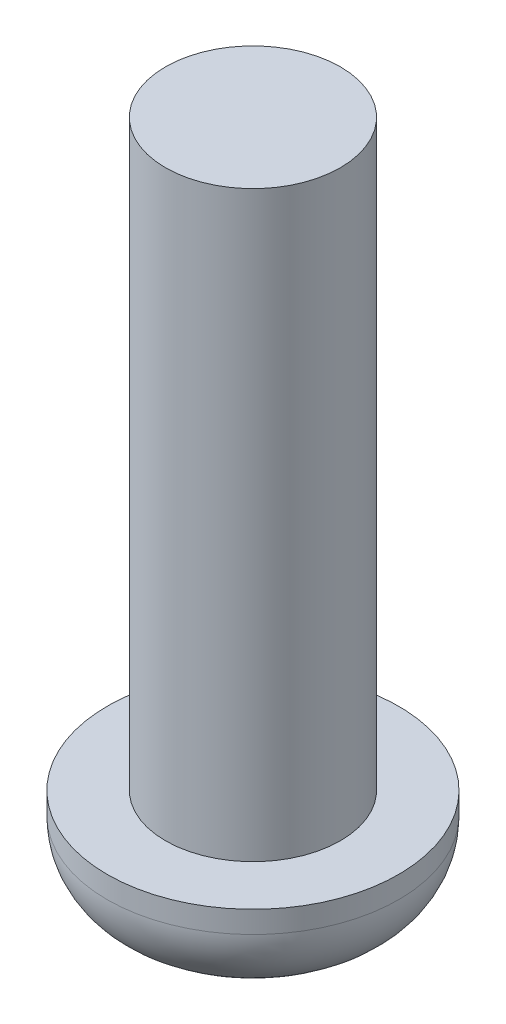
from build123d import *

# Parameters (mm, degrees)
SKETCH1_R           = 4
BOSS_EXTRUDE1_DEPTH = 2.6
SKETCH2_R           = 2.4
BOSS_EXTRUDE2_DEPTH = 16
FILLET1_R           = 2


with BuildPart() as part:
    # Sketch1 → Boss-Extrude1 (new body)
    with BuildSketch(Plane(origin=(0, 0, 0), x_dir=(1, 0, 0), z_dir=(0, 1, 0))):
        Circle(SKETCH1_R)
    extrude(amount=BOSS_EXTRUDE1_DEPTH)

    # Sketch2 → Boss-Extrude2 (add)
    with BuildSketch(Plane(origin=(0, 2.6, 0), x_dir=(1, 0, 0), z_dir=(0, 1, 0))):
        Circle(SKETCH2_R)
    extrude(amount=BOSS_EXTRUDE2_DEPTH)

    # Fillet1
    fillet1_edges = [part.edges().sort_by_distance(p)[0] for p in [
        (-4, 0, 0),
    ]]
    fillet(fillet1_edges, radius=FILLET1_R)


solid = part.part
